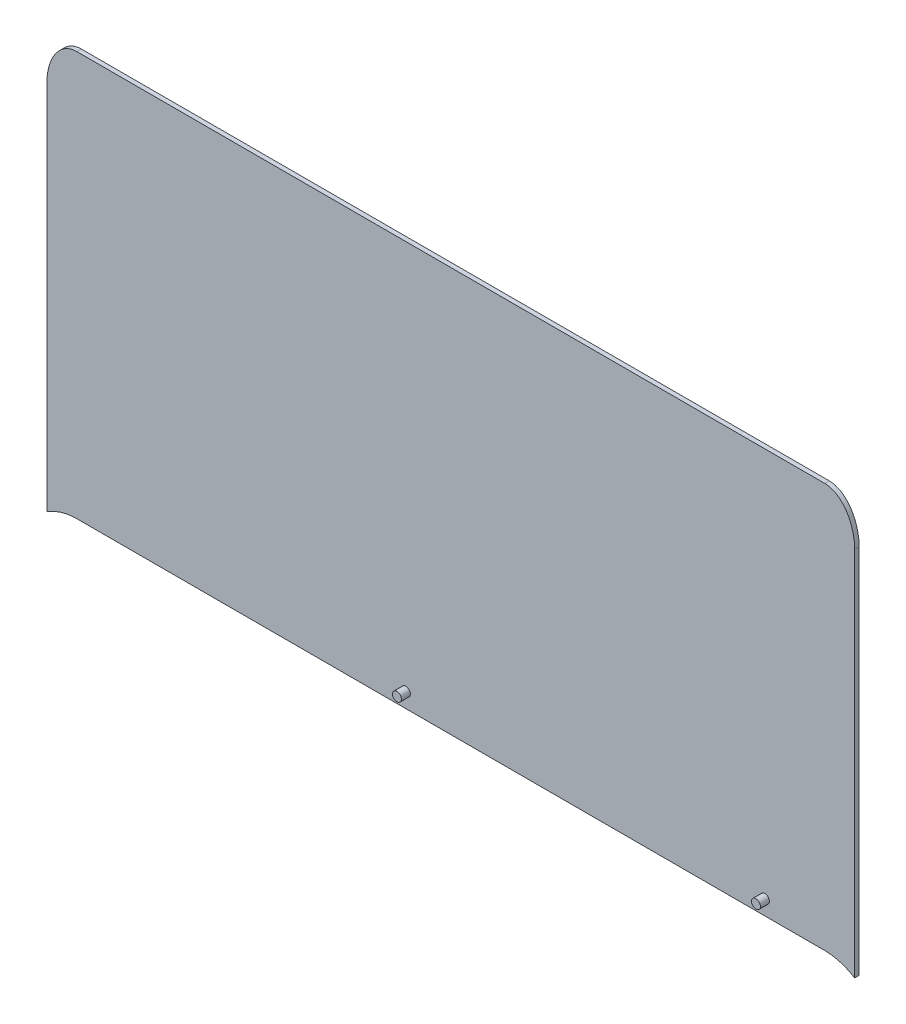
from build123d import *

# Parameters (mm, degrees)
BOSS_EXTRUDE1_DEPTH = 3
SKETCH2_R           = 3
BOSS_EXTRUDE2_DEPTH = 6


with BuildPart() as part:
    # Sketch1 → Boss-Extrude1 (new body)
    with BuildSketch(Plane.XY):
        with BuildLine():
            Line((250, 382.208907076), (-250, 382.208907076))
            add(Edge.make_bspline(
                [(-250, 382.208907076), (-260.435607626, 382.208907076), (-270, 376.305635941)],
                knots=[0, 0, 0, 0.411516846, 0.411516846, 0.411516846], degree=2, weights=[1, 0.978906313, 1]))
            Line((-270, 376.305635941), (-270, 624.340941432))
            add(Edge.make_bspline(
                [(-250, 652.625212679), (-270, 652.625212679), (-270, 624.340941432)],
                knots=[0, 0, 0, 1.570796327, 1.570796327, 1.570796327], degree=2, weights=[1, 0.707106781, 1]))
            Line((-250, 652.625212679), (250, 652.625212679))
            add(Edge.make_bspline(
                [(270, 624.340941432), (270, 652.625212679), (250, 652.625212679)],
                knots=[1.570796327, 1.570796327, 1.570796327, 3.141592654, 3.141592654, 3.141592654], degree=2, weights=[1, 0.707106781, 1]))
            Line((270, 624.340941432), (270, 376.305635941))
            add(Edge.make_bspline(
                [(270, 376.305635941), (260.435607626, 382.208907076), (250, 382.208907076)],
                knots=[2.730075808, 2.730075808, 2.730075808, 3.141592654, 3.141592654, 3.141592654], degree=2, weights=[1, 0.978906313, 1]))
        make_face()
    extrude(amount=-BOSS_EXTRUDE1_DEPTH)

    # Sketch2 → Boss-Extrude2 (add)
    with BuildSketch(Plane.XY):
        with Locations((-30, 392.208907076)):
            Circle(SKETCH2_R)
        with Locations((210, 392.208907076)):
            Circle(SKETCH2_R)
    extrude(amount=BOSS_EXTRUDE2_DEPTH)


solid = part.part
